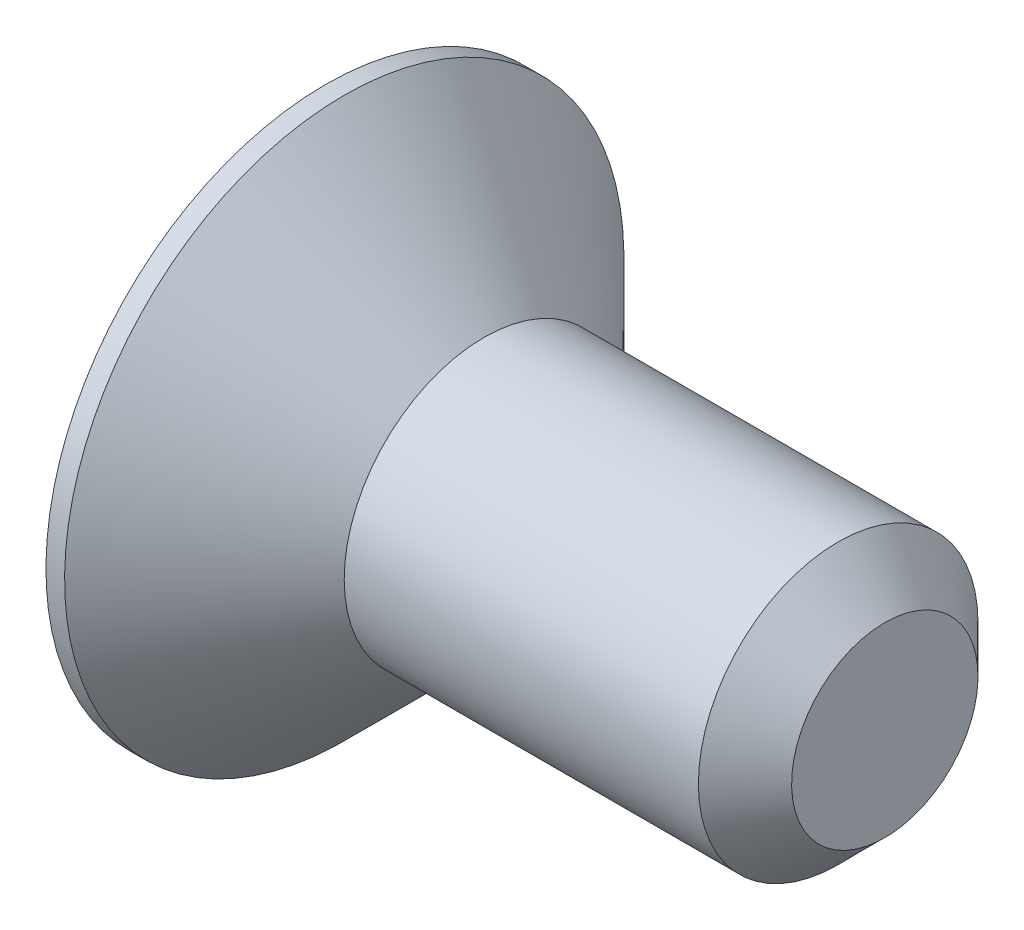
from build123d import *

# Parameters (mm, degrees)
CHANFREIN1_SIZE         = 0.5
ENL_V_MAT_EXTRU_1_DEPTH = 1.2


with BuildPart() as part:
    # Esquisse1 → Révolution1 (revolve)
    with BuildSketch(Plane.XY):
        Polygon((0, 0), (0, 3), (0.2, 3), (1.7, 1.5), (6, 1.5), (6, 0), align=None)
    revolve(axis=Axis((6, 0, 0), (-1, 0, 0)))

    # Chanfrein1
    chanfrein1_edges = [part.edges().sort_by_distance(p)[0] for p in [
        (6, -1.5, 0),
    ]]
    chamfer(chanfrein1_edges, length=CHANFREIN1_SIZE)

    # Esquisse2 → Enlèv. mat.-Extru.1 (cut)
    with BuildSketch(Plane.ZY):
        Polygon((0, 1.154700538), (-1, 0.577350269), (-1, -0.577350269), (0, -1.154700538), (1, -0.577350269), (1, 0.577350269), align=None)
    extrude(amount=-ENL_V_MAT_EXTRU_1_DEPTH, mode=Mode.SUBTRACT)


solid = part.part
